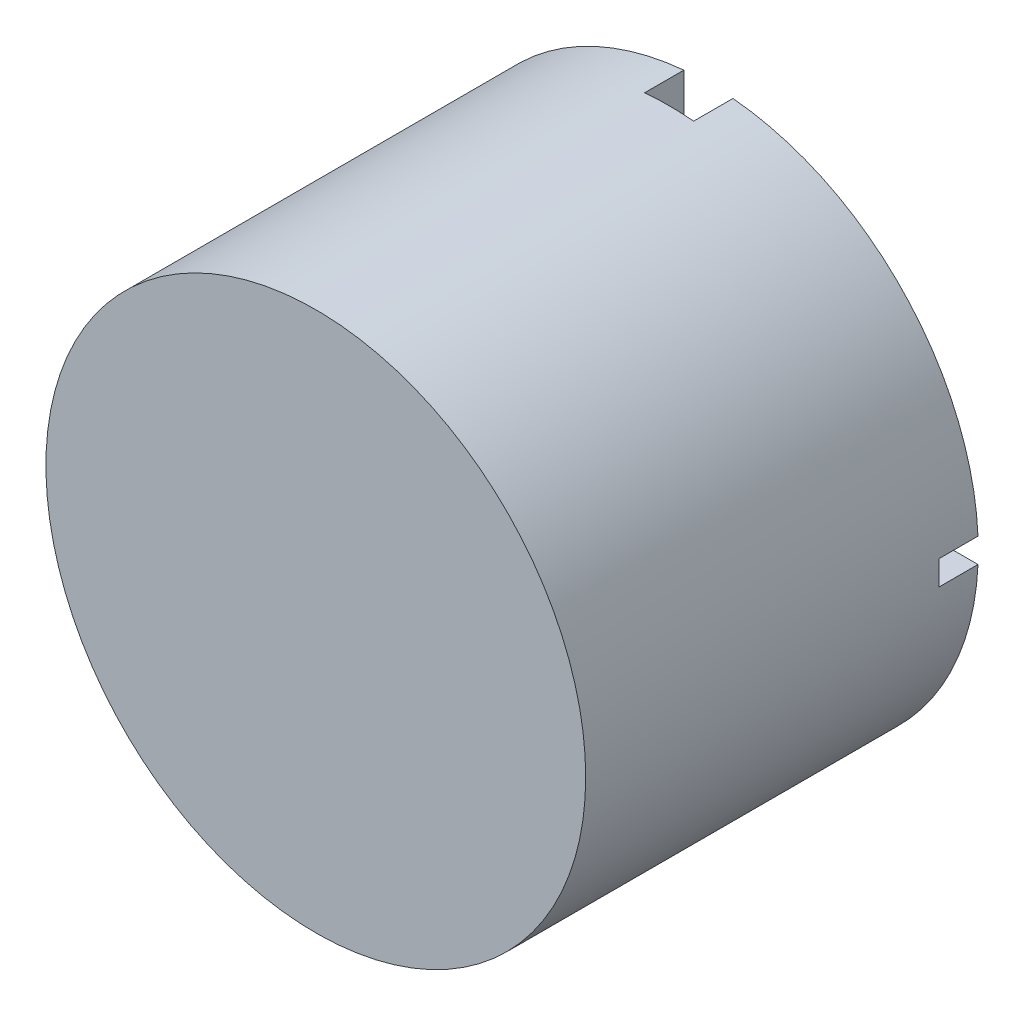
from build123d import *

# Parameters (mm, degrees)
SKETCH1_R           = 17.4625
BOSS_EXTRUDE1_DEPTH = 25.4
CUT_EXTRUDE1_DEPTH  = 2.54


with BuildPart() as part:
    # Sketch1 → Boss-Extrude1 (new body)
    with BuildSketch(Plane.XY):
        Circle(SKETCH1_R)
    extrude(amount=BOSS_EXTRUDE1_DEPTH)

    # Sketch2 → Cut-Extrude1 (cut)
    with BuildSketch(Plane(origin=(0, 0, 0), x_dir=(-1, 0, 0), z_dir=(0, 0, -1))):
        Polygon((1.5875, 0.79375), (23.225772956, 0.79375), (23.225772956, -0.79375), (1.5875, -0.79375), (1.5875, -19.542370193), (-1.5875, -19.542370193), (-1.5875, -0.79375), (-24.356135007, -0.79375), (-24.356135007, 0.79375), (-1.5875, 0.79375), (-1.5875, 20.58214549), (1.5875, 20.58214549), align=None)
    extrude(amount=-CUT_EXTRUDE1_DEPTH, mode=Mode.SUBTRACT)


solid = part.part
